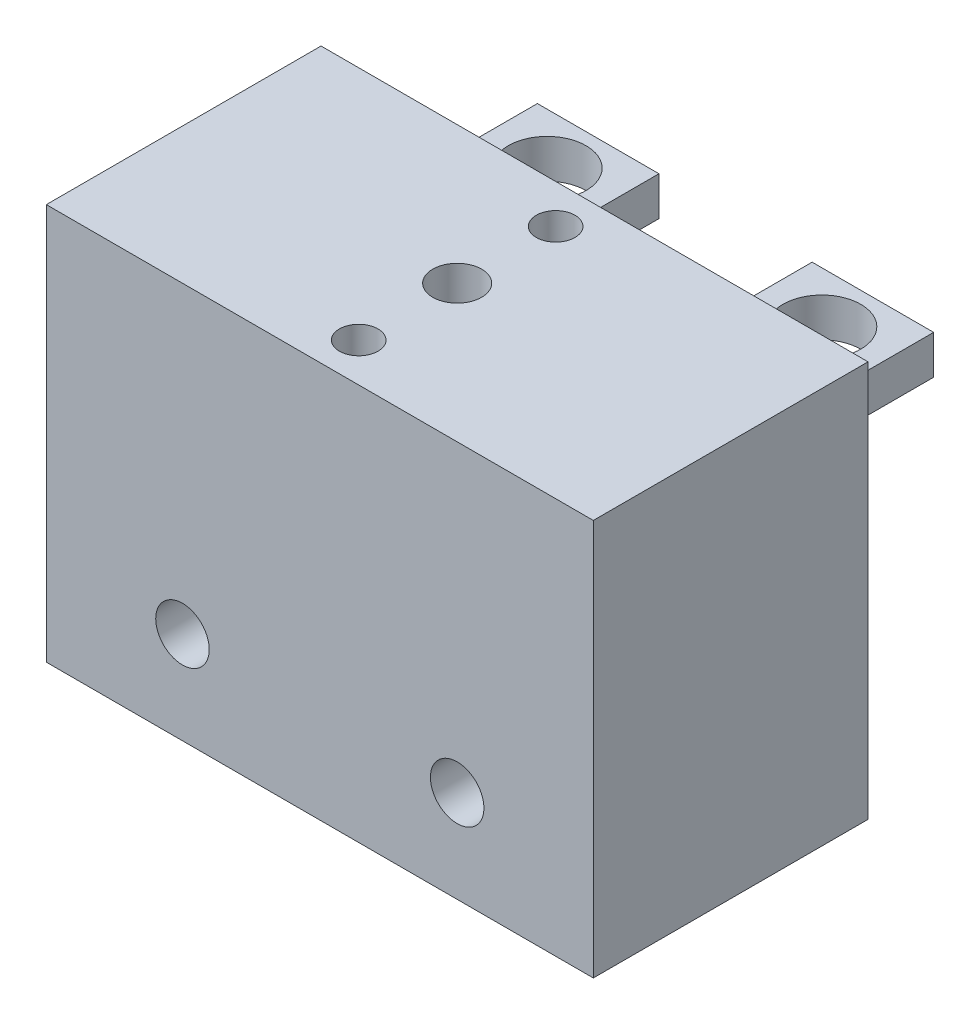
from build123d import *

# Parameters (mm, degrees)
SKETCH1_W          = 57.15
SKETCH1_H          = 28.702
EXTRUDE1_DEPTH     = 41.402
SKETCH2_R          = 2.5527
CUT_EXTRUDE1_DEPTH = 42.402
SKETCH3_R          = 2.0193
CUT_EXTRUDE2_DEPTH = 25.4
SKETCH8_R          = 2.794
CUT_EXTRUDE3_DEPTH = 29.702
SKETCH9_W          = 12.7
SKETCH9_H          = 4.064
EXTRUDE2_DEPTH     = 14.732
SKETCH10_R         = 4.064
CUT_EXTRUDE4_DEPTH = 33.766


with BuildPart() as part:
    # Sketch1 → Extrude1 (new body)
    with BuildSketch(Plane(origin=(0, 0, 0), x_dir=(1, 0, 0), z_dir=(0, 1, 0))):
        with Locations((28.575, 14.351)):
            Rectangle(SKETCH1_W, SKETCH1_H)
    extrude(amount=EXTRUDE1_DEPTH)

    # Sketch2 → Cut-Extrude1 (cut, through all)
    with BuildSketch(Plane(origin=(0, 41.402, 0), x_dir=(-1, 0, 0), z_dir=(0, 1, 0))):
        with Locations((-28.575, -14.351)):
            Circle(SKETCH2_R)
    extrude(amount=-CUT_EXTRUDE1_DEPTH, mode=Mode.SUBTRACT)

    # Sketch3 → Cut-Extrude2 (cut)
    with BuildSketch(Plane(origin=(0, 41.402, 0), x_dir=(-1, 0, 0), z_dir=(0, 1, 0))):
        with Locations((-28.575, -24.638)):
            Circle(SKETCH3_R)
        with Locations((-28.575, -4.064)):
            Circle(SKETCH3_R)
    extrude(amount=-CUT_EXTRUDE2_DEPTH, mode=Mode.SUBTRACT)

    # Sketch8 → Cut-Extrude3 (cut, through all)
    with BuildSketch(Plane(origin=(0, 0, -28.702), x_dir=(-1, 0, 0), z_dir=(0, 0, -1))):
        with Locations((-42.926, 9.652)):
            Circle(SKETCH8_R)
        with Locations((-14.224, 9.652)):
            Circle(SKETCH8_R)
    extrude(amount=-CUT_EXTRUDE3_DEPTH, mode=Mode.SUBTRACT)

    # Sketch9 → Extrude2 (add)
    with BuildSketch(Plane(origin=(0, 0, -28.702), x_dir=(-1, 0, 0), z_dir=(0, 0, -1))):
        with Locations((-42.926, 30.734)):
            Rectangle(SKETCH9_W, SKETCH9_H)
        with Locations((-14.224, 30.734)):
            Rectangle(SKETCH9_W, SKETCH9_H)
    extrude(amount=EXTRUDE2_DEPTH)

    # Sketch10 → Cut-Extrude4 (cut, through all)
    with BuildSketch(Plane(origin=(0, 32.766, 0), x_dir=(-1, 0, 0), z_dir=(0, 1, 0))):
        with Locations((-42.926, -38.1)):
            Circle(SKETCH10_R)
        with Locations((-14.224, -38.1)):
            Circle(SKETCH10_R)
    extrude(amount=-CUT_EXTRUDE4_DEPTH, mode=Mode.SUBTRACT)


solid = part.part
